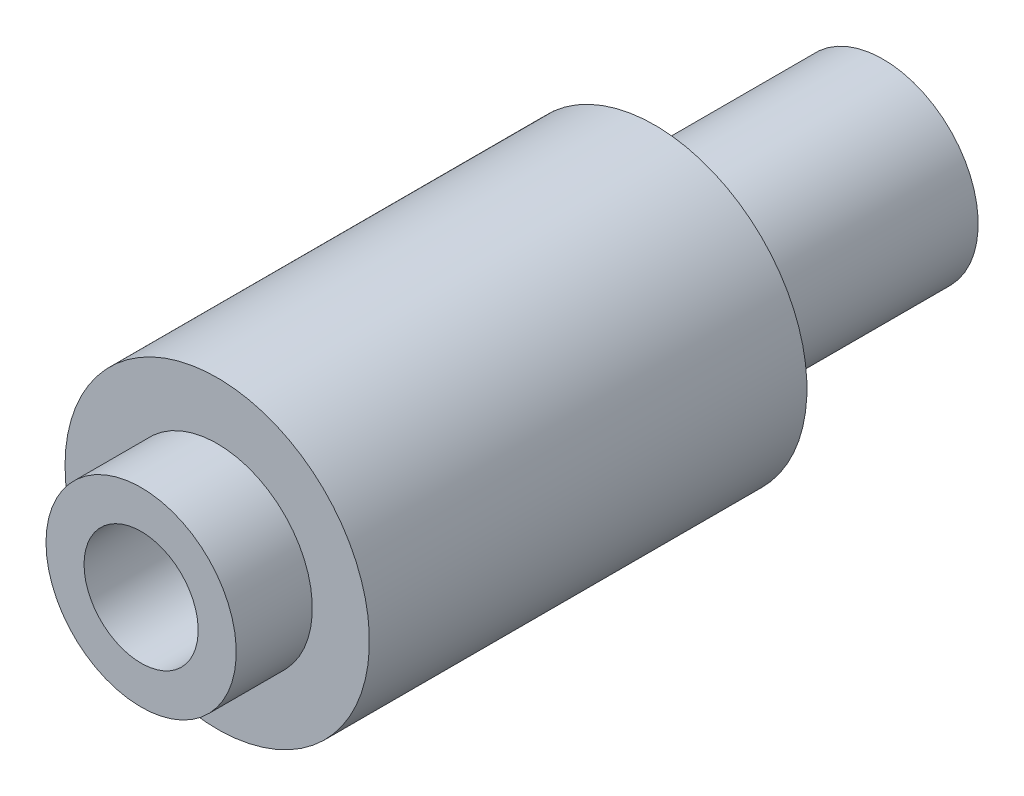
from build123d import *

# Parameters (mm, degrees)
SHELL1_T = -1


with BuildPart() as part:
    # Sketch1 → Revolve1 (revolve)
    with BuildSketch(Plane(origin=(0, 0, 0), x_dir=(1, 0, 0), z_dir=(0, 1, 0)), mode=Mode.PRIVATE) as revolve1_sk:
        Polygon((0, 9.75), (2.5, 9.75), (2.5, 3.75), (4, 3.75), (4, -7.75), (2.5, -7.75), (2.5, -9.75), (0, -9.75), align=None)
    revolve(revolve1_sk.sketch.rotate(Axis((0, 0, -28.532608696), (0, 0, 1)), 180), axis=Axis((0, 0, -28.532608696), (0, 0, 1)))

    # Shell1
    shell1_openings = [part.faces().sort_by_distance(p)[0] for p in [
        (0, 0, 9.75),
        (0, 0, -9.75),
    ]]
    offset(amount=SHELL1_T, openings=shell1_openings, kind=Kind.INTERSECTION)


solid = part.part
